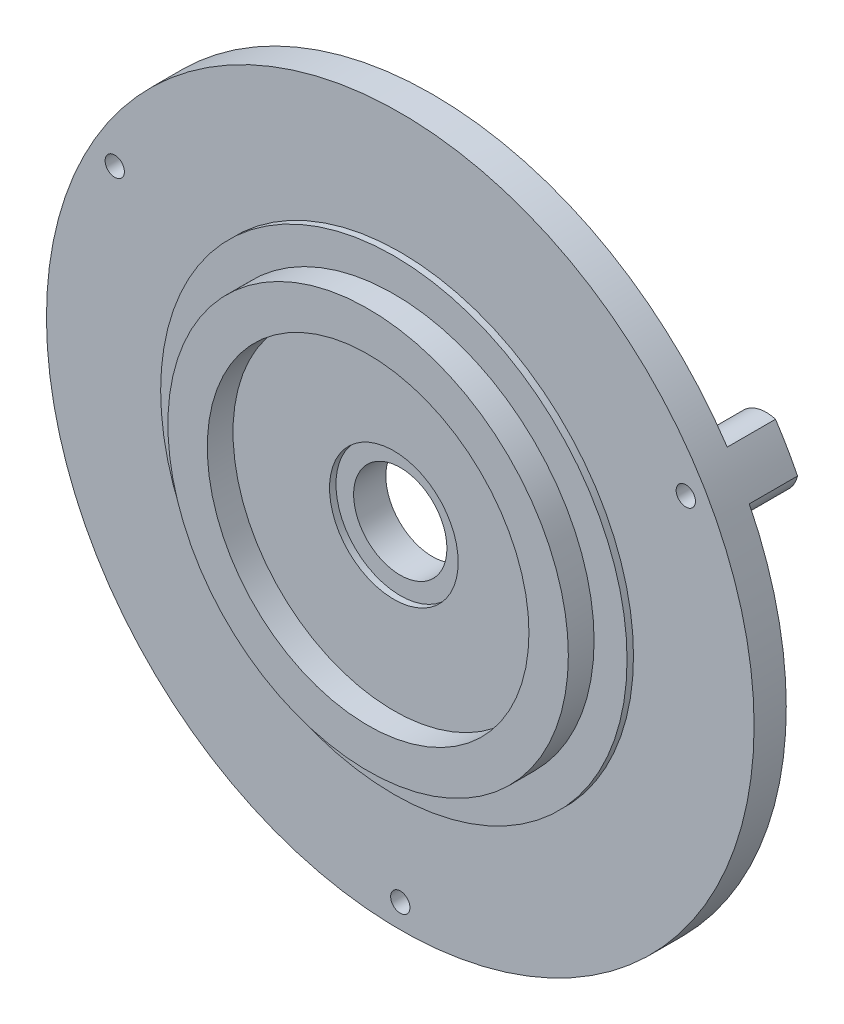
from build123d import *

# Parameters (mm, degrees)
SKETCH_1_R          = 22
EXTRUDE_1_DEPTH     = 2
SKETCH_2_R          = 12.45
SKETCH_2_R_2        = 10
EXTRUDE_2_DEPTH     = 2
SKETCH_3_R          = 2.9
CUT_EXTRUDE_1_DEPTH = 11
EXTRUDE_3_DEPTH     = 3
SKETCH_5_R          = 0.6
CUT_EXTRUDE_2_DEPTH = 16
SKETCH_6_R          = 14.5
SKETCH_6_R_2        = 4
EXTRUDE_4_DEPTH     = 0.4


with BuildPart() as part:
    # 草图1 → 凸台-拉伸1 (new body)
    with BuildSketch(Plane.XY):
        Circle(SKETCH_1_R)
    extrude(amount=EXTRUDE_1_DEPTH)

    # 草图2 → 凸台-拉伸2 (add)
    with BuildSketch(Plane.XY.offset(2)):
        Circle(SKETCH_2_R)
        Circle(SKETCH_2_R_2, mode=Mode.SUBTRACT)
    extrude(amount=EXTRUDE_2_DEPTH)

    # 草图3 → 切除-拉伸1 (cut)
    with BuildSketch(Plane.XY.offset(2)):
        Circle(SKETCH_3_R)
    extrude(amount=-CUT_EXTRUDE_1_DEPTH, mode=Mode.SUBTRACT)

    # 草图4 → 凸台-拉伸3 (add)
    with BuildSketch(Plane(origin=(0, 0, 0), x_dir=(-1, 0, 0), z_dir=(0, 0, -1))):
        with BuildLine():
            ThreePointArc((1.369754339, -21.957317073), (0, -18.5), (-1.369754339, -21.957317073))
            ThreePointArc((-1.369754339, -21.957317073), (0, -22), (1.369754339, -21.957317073))
        make_face()
        with BuildLine():
            ThreePointArc((-19.700471554, 9.792416482), (-16.02146997, 9.25), (-18.330717215, 12.164900591))
            ThreePointArc((-18.330717215, 12.164900591), (-19.052558883, 11), (-19.700471554, 9.792416482))
        make_face()
        with BuildLine():
            ThreePointArc((18.330717215, 12.164900591), (16.02146997, 9.25), (19.700471554, 9.792416482))
            ThreePointArc((19.700471554, 9.792416482), (19.052558883, 11), (18.330717215, 12.164900591))
        make_face()
    extrude(amount=EXTRUDE_3_DEPTH)

    # 草图5 → 切除-拉伸2 (cut)
    with BuildSketch(Plane(origin=(0, 0, -3), x_dir=(-1, 0, 0), z_dir=(0, 0, -1))):
        with Locations((0, -20.5)):
            Circle(SKETCH_5_R)
        with Locations((-17.753520778, 10.25)):
            Circle(SKETCH_5_R)
        with Locations((17.753520778, 10.25)):
            Circle(SKETCH_5_R)
    extrude(amount=-CUT_EXTRUDE_2_DEPTH, mode=Mode.SUBTRACT)

    # 草图6 → 凸台-拉伸4 (add)
    with BuildSketch(Plane.XY.offset(2)):
        Circle(SKETCH_6_R)
        Circle(SKETCH_6_R_2, mode=Mode.SUBTRACT)
    extrude(amount=EXTRUDE_4_DEPTH)


solid = part.part
